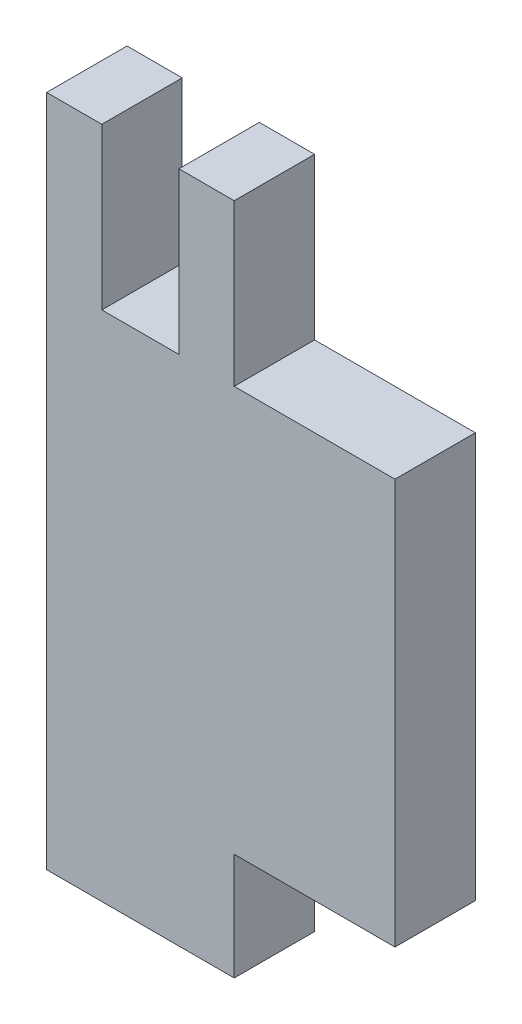
from build123d import *

# Parameters (mm, degrees)
SALIENTE_EXTRUIR2_DEPTH = 3


with BuildPart() as part:
    # Croquis1 → Saliente-Extruir2 (new body)
    with BuildSketch(Plane.XY):
        Polygon((4.937, 25.123), (7, 25.123), (7, 19.123), (13, 19.123), (13, 4), (7, 4), (7, 0), (0, 0), (0, 25.123), (2.06, 25.123), (2.06, 19.123), (4.937, 19.123), align=None)
    extrude(amount=SALIENTE_EXTRUIR2_DEPTH)


solid = part.part
